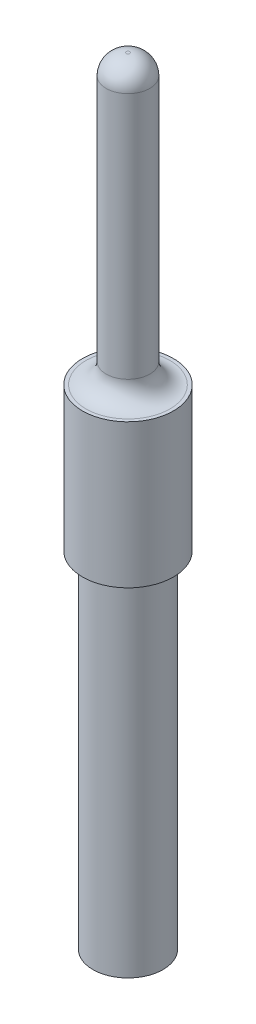
from build123d import *

# Parameters (mm, degrees)
SKETCH1_R           = 0.61
SKETCH1_R_2         = 0.5
BOSS_EXTRUDE1_DEPTH = 6
SKETCH2_R           = 0.79
BOSS_EXTRUDE2_DEPTH = 2.5
SKETCH3_R           = 0.38
BOSS_EXTRUDE3_DEPTH = 5
FILLET1_R           = 0.35
FILLET2_R           = 0.35


with BuildPart() as part:
    # Sketch1 → Boss-Extrude1 (new body)
    with BuildSketch(Plane(origin=(0, 0, 0), x_dir=(1, 0, 0), z_dir=(0, 1, 0))):
        Circle(SKETCH1_R)
        Circle(SKETCH1_R_2, mode=Mode.SUBTRACT)
    extrude(amount=BOSS_EXTRUDE1_DEPTH)

    # Sketch2 → Boss-Extrude2 (add)
    with BuildSketch(Plane(origin=(0, 6, 0), x_dir=(1, 0, 0), z_dir=(0, 1, 0))):
        Circle(SKETCH2_R)
    extrude(amount=BOSS_EXTRUDE2_DEPTH)

    # Sketch3 → Boss-Extrude3 (add)
    with BuildSketch(Plane(origin=(0, 8.5, 0), x_dir=(1, 0, 0), z_dir=(0, 1, 0))):
        Circle(SKETCH3_R)
    extrude(amount=BOSS_EXTRUDE3_DEPTH)

    # Fillet1
    fillet1_edges = [part.edges().sort_by_distance(p)[0] for p in [
        (-0.38, 13.5, 0),
    ]]
    fillet(fillet1_edges, radius=FILLET1_R)

    # Fillet2
    fillet2_edges = [part.edges().sort_by_distance(p)[0] for p in [
        (-0.38, 8.5, 0),
    ]]
    fillet(fillet2_edges, radius=FILLET2_R)


solid = part.part
